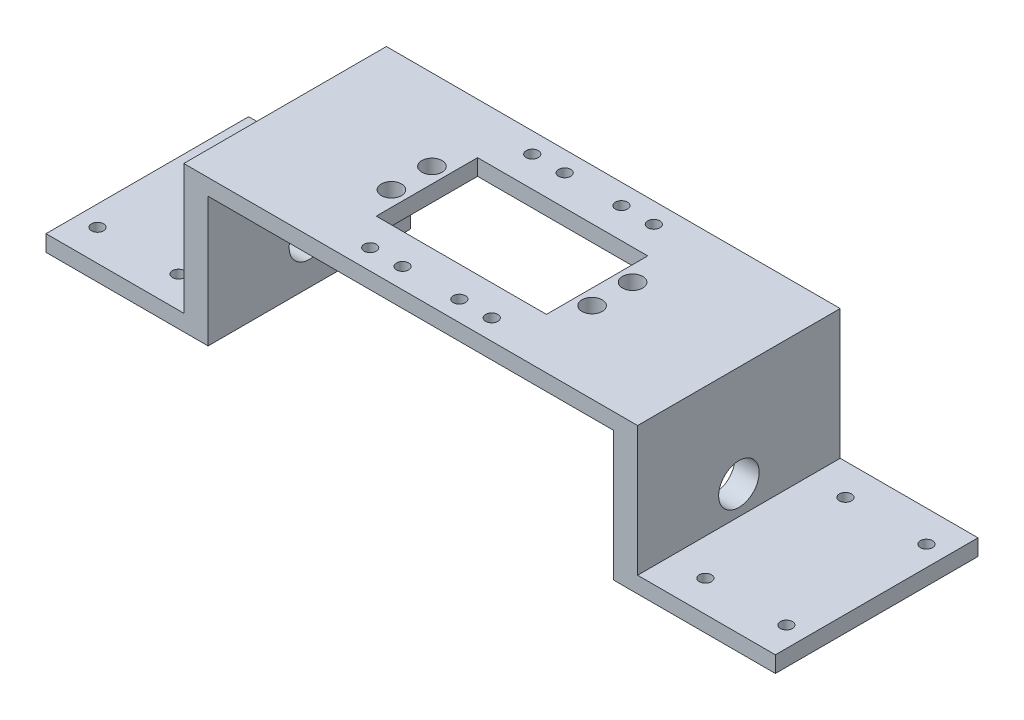
from build123d import *

# Parameters (mm, degrees)
EXTRUDE_1_DEPTH     = 50
SKETCH_2_W          = 42
SKETCH_2_H          = 25
CUT_EXTRUDE_1_DEPTH = 37
SKETCH_3_R          = 2.5
CUT_EXTRUDE_2_DEPTH = 37
SKETCH_4_R          = 5
CUT_EXTRUDE_3_DEPTH = 147
SKETCH_5_R          = 1.5
CUT_EXTRUDE_4_DEPTH = 5
SKETCH_6_R          = 1.5
CUT_EXTRUDE_5_DEPTH = 37


with BuildPart() as part:
    # 草图1 → 凸台-拉伸1 (new body)
    with BuildSketch(Plane.XY):
        Polygon((90, 0), (90, 4), (56, 4), (56, 36), (-56, 36), (-56, 4), (-90, 4), (-90, 0), (-50, 0), (-50, 32), (50, 32), (50, 0), align=None)
    extrude(amount=-EXTRUDE_1_DEPTH)

    # 草图2 → 切除-拉伸1 (cut, through all)
    with BuildSketch(Plane(origin=(0, 36, 0), x_dir=(1, 0, 0), z_dir=(0, 1, 0))):
        with Locations((0, 25)):
            Rectangle(SKETCH_2_W, SKETCH_2_H)
    extrude(amount=-CUT_EXTRUDE_1_DEPTH, mode=Mode.SUBTRACT)

    # 草图3 → 切除-拉伸2 (cut, through all)
    with BuildSketch(Plane(origin=(0, 36, 0), x_dir=(1, 0, 0), z_dir=(0, 1, 0))):
        with Locations((-24.76, 30)):
            Circle(SKETCH_3_R)
        with Locations((24.76, 30)):
            Circle(SKETCH_3_R)
        with Locations((24.76, 20)):
            Circle(SKETCH_3_R)
        with Locations((-24.76, 20)):
            Circle(SKETCH_3_R)
    extrude(amount=-CUT_EXTRUDE_2_DEPTH, mode=Mode.SUBTRACT)

    # 草图4 → 切除-拉伸3 (cut, through all)
    with BuildSketch(Plane(origin=(56, 0, 0), x_dir=(0, 0, -1), z_dir=(1, 0, 0))):
        with Locations((25, 11)):
            Circle(SKETCH_4_R)
    extrude(amount=-CUT_EXTRUDE_3_DEPTH, mode=Mode.SUBTRACT)

    # 草图5 → 切除-拉伸4 (cut, through all)
    with BuildSketch(Plane(origin=(0, 4, 0), x_dir=(1, 0, 0), z_dir=(0, 1, 0))):
        with Locations((-36.607969405, 54.749619062)):
            Circle(SKETCH_5_R)
        with Locations((-65, 42.286041433)):
            Circle(SKETCH_5_R)
        with Locations((-65, 7.713958567)):
            Circle(SKETCH_5_R)
        with Locations((-36.607969405, -4.749619062)):
            Circle(SKETCH_5_R)
        with Locations((36.607969405, -4.749619062)):
            Circle(SKETCH_5_R)
        with Locations((65, 7.713958567)):
            Circle(SKETCH_5_R)
        with Locations((65, 42.286041433)):
            Circle(SKETCH_5_R)
        with Locations((36.607969405, 54.749619062)):
            Circle(SKETCH_5_R)
        with Locations((85, 7.713958567)):
            Circle(SKETCH_5_R)
        with Locations((85, 42.286041433)):
            Circle(SKETCH_5_R)
        with Locations((-85, 42.286041433)):
            Circle(SKETCH_5_R)
        with Locations((-85, 7.713958567)):
            Circle(SKETCH_5_R)
    extrude(amount=-CUT_EXTRUDE_4_DEPTH, mode=Mode.SUBTRACT)

    # 草图6 → 切除-拉伸5 (cut, through all)
    with BuildSketch(Plane(origin=(0, 36, 0), x_dir=(1, 0, 0), z_dir=(0, 1, 0))):
        with Locations((-7, 45)):
            Circle(SKETCH_6_R)
        with Locations((7, 45)):
            Circle(SKETCH_6_R)
        with Locations((-15, 45)):
            Circle(SKETCH_6_R)
        with Locations((15, 45)):
            Circle(SKETCH_6_R)
        with Locations((15, 5)):
            Circle(SKETCH_6_R)
        with Locations((7, 5)):
            Circle(SKETCH_6_R)
        with Locations((-7, 5)):
            Circle(SKETCH_6_R)
        with Locations((-15, 5)):
            Circle(SKETCH_6_R)
    extrude(amount=-CUT_EXTRUDE_5_DEPTH, mode=Mode.SUBTRACT)


solid = part.part
